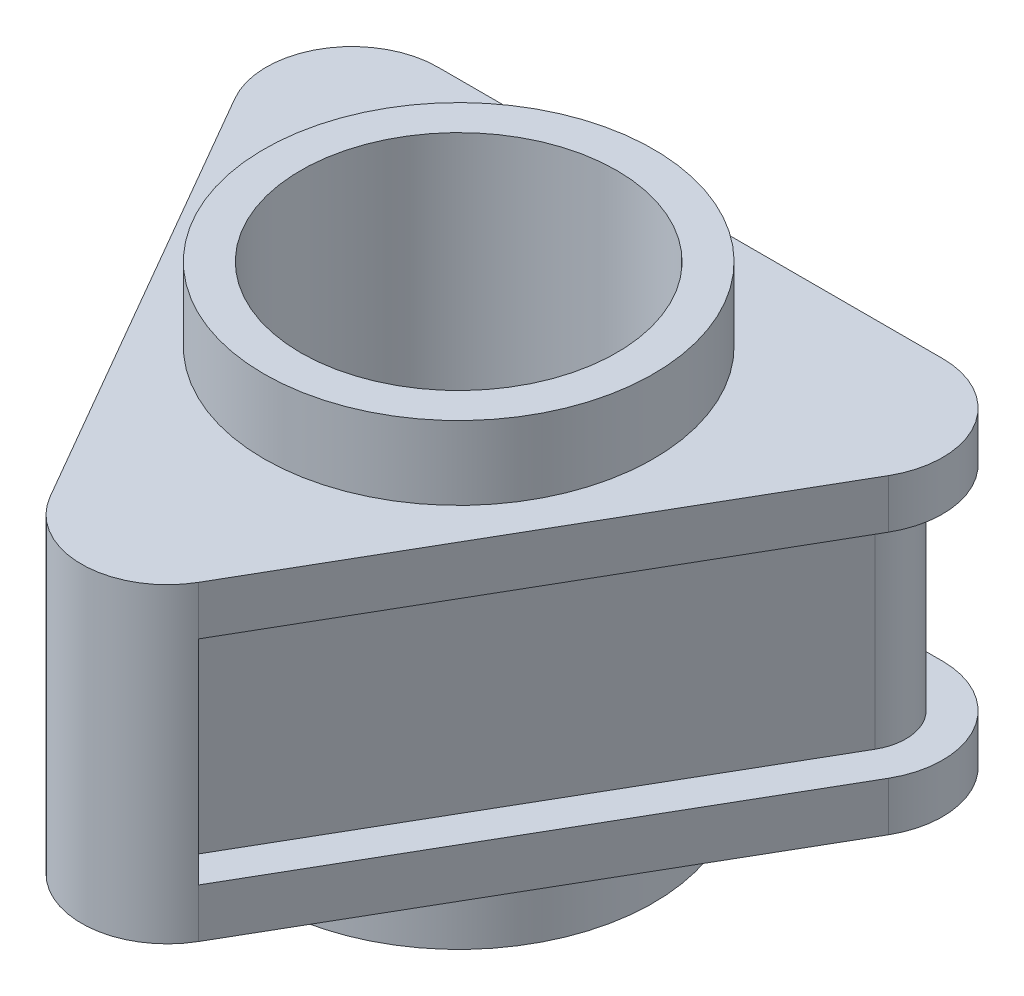
from build123d import *

# Parameters (mm, degrees)
SKETCH1_R                = 6.45
BOSS_EXTRUDE1_DEPTH      = 6.35
FILLET1_R                = 2
SKETCH3_R                = 7.95
SKETCH3_R_2              = 6.45
BOSS_EXTRUDE3_DEPTH      = 3
BOSS_EXTRUDE3_DEPTH_BACK = 15.7
BOSS_EXTRUDE4_DEPTH      = 2
BOSS_EXTRUDE5_DEPTH      = 2
BOSS_EXTRUDE6_DEPTH      = 8.7


with BuildPart() as part:
    # Sketch1 → Boss-Extrude1 (new body, symmetric)
    with BuildSketch(Plane(origin=(0, 0, 0), x_dir=(1, 0, 0), z_dir=(0, 1, 0))):
        Polygon((0, -15.9), (13.76980392, 7.95), (-13.76980392, 7.95), align=None)
        with Locations(Location((0, 0, 0), (0, 0, 270))):  # turned: the seam where the file's is
            Circle(SKETCH1_R, mode=Mode.SUBTRACT)
    extrude(amount=BOSS_EXTRUDE1_DEPTH, both=True)

    # Fillet1
    fillet1_edges = [part.edges().sort_by_distance(p)[0] for p in [
        (-13.76980392, 0, -7.95),
        (13.76980392, 0, -7.95),
        (0, 0, 15.9),
    ]]
    fillet(fillet1_edges, radius=FILLET1_R)

    # Sketch3 → Boss-Extrude3 (add, two sides)
    with BuildSketch(Plane(origin=(0, 6.35, 0), x_dir=(1, 0, 0), z_dir=(0, 1, 0))) as boss_extrude3_sk:
        with Locations(Location((0, 0, 0), (0, 0, 270))):  # turned: the seam where the file's is
            Circle(SKETCH3_R)
        with Locations(Location((0, 0, 0), (0, 0, 270))):  # turned: the seam where the file's is
            Circle(SKETCH3_R_2, mode=Mode.SUBTRACT)
    extrude(amount=BOSS_EXTRUDE3_DEPTH)
    extrude(boss_extrude3_sk.sketch, amount=-BOSS_EXTRUDE3_DEPTH_BACK)

    # Sketch4 → Boss-Extrude4 (add)
    with BuildSketch(Plane(origin=(0, 6.35, 0), x_dir=(1, 0, 0), z_dir=(0, 1, 0))):
        with BuildLine():
            Line((8.183940066, -4.725), (13.336791218, 4.2))
            ThreePointArc((13.336791218, 4.2), (13.336791218, 7.7), (10.305702305, 9.45))
            Line((10.305702305, 9.45), (0, 9.45))
            Line((0, 9.45), (-10.305702305, 9.45))
            ThreePointArc((-10.305702305, 9.45), (-13.336791218, 7.7), (-13.336791218, 4.2))
            Line((-13.336791218, 4.2), (-8.183940066, -4.725))
            Line((-8.183940066, -4.725), (-3.031088913, -13.65))
            ThreePointArc((-3.031088913, -13.65), (0, -15.4), (3.031088913, -13.65))
            Line((3.031088913, -13.65), (8.183940066, -4.725))
        make_face()
        with BuildLine():
            Line((6.88490196, -3.975), (12.037753113, 4.95))
            ThreePointArc((12.037753113, 4.95), (12.037753113, 6.95), (10.305702305, 7.95))
            Line((10.305702305, 7.95), (0, 7.95))
            Line((0, 7.95), (-10.305702305, 7.95))
            ThreePointArc((-10.305702305, 7.95), (-12.037753113, 6.95), (-12.037753113, 4.95))
            Line((-12.037753113, 4.95), (-6.88490196, -3.975))
            Line((-6.88490196, -3.975), (-1.732050808, -12.9))
            ThreePointArc((-1.732050808, -12.9), (0, -13.9), (1.732050808, -12.9))
            Line((1.732050808, -12.9), (6.88490196, -3.975))
        make_face(mode=Mode.SUBTRACT)
    extrude(amount=-BOSS_EXTRUDE4_DEPTH)

    # Sketch5 → Boss-Extrude5 (add)
    with BuildSketch(Plane.XZ.offset(6.35)):
        with BuildLine():
            Line((13.336791218, -4.2), (3.031088913, 13.65))
            ThreePointArc((3.031088913, 13.65), (0, 15.4), (-3.031088913, 13.65))
            Line((-3.031088913, 13.65), (-13.336791218, -4.2))
            ThreePointArc((-13.336791218, -4.2), (-13.336791218, -7.7), (-10.305702305, -9.45))
            Line((-10.305702305, -9.45), (10.305702305, -9.45))
            ThreePointArc((10.305702305, -9.45), (13.336791218, -7.7), (13.336791218, -4.2))
        make_face()
        with BuildLine():
            Line((10.305702305, -7.95), (-10.305702305, -7.95))
            ThreePointArc((-10.305702305, -7.95), (-12.037753113, -6.95), (-12.037753113, -4.95))
            Line((-12.037753113, -4.95), (-1.732050808, 12.9))
            ThreePointArc((-1.732050808, 12.9), (0, 13.9), (1.732050808, 12.9))
            Line((1.732050808, 12.9), (12.037753113, -4.95))
            ThreePointArc((12.037753113, -4.95), (12.037753113, -6.95), (10.305702305, -7.95))
        make_face(mode=Mode.SUBTRACT)
    extrude(amount=-BOSS_EXTRUDE5_DEPTH)

    # Sketch6 → Boss-Extrude6 (add)
    with BuildSketch(Plane.XZ.offset(-4.35)):
        with BuildLine():
            Line((-2.165063509, 13.15), (-3.031088913, 13.65))
            ThreePointArc((-3.031088913, 13.65), (0, 15.4), (3.031088913, 13.65))
            Line((3.031088913, 13.65), (2.165063509, 13.15))
            ThreePointArc((2.165063509, 13.15), (1.864007283, 13.565976245), (1.484313483, 13.911669328))
            Line((1.484313483, 13.911669328), (1, 13.632050808))
            ThreePointArc((1, 13.632050808), (0, 13.9), (-1, 13.632050808))
            Line((-1, 13.632050808), (-1.484313483, 13.911669328))
            ThreePointArc((-1.484313483, 13.911669328), (-1.864007283, 13.565976245), (-2.165063509, 13.15))
        make_face()
    extrude(amount=BOSS_EXTRUDE6_DEPTH)


solid = part.part
